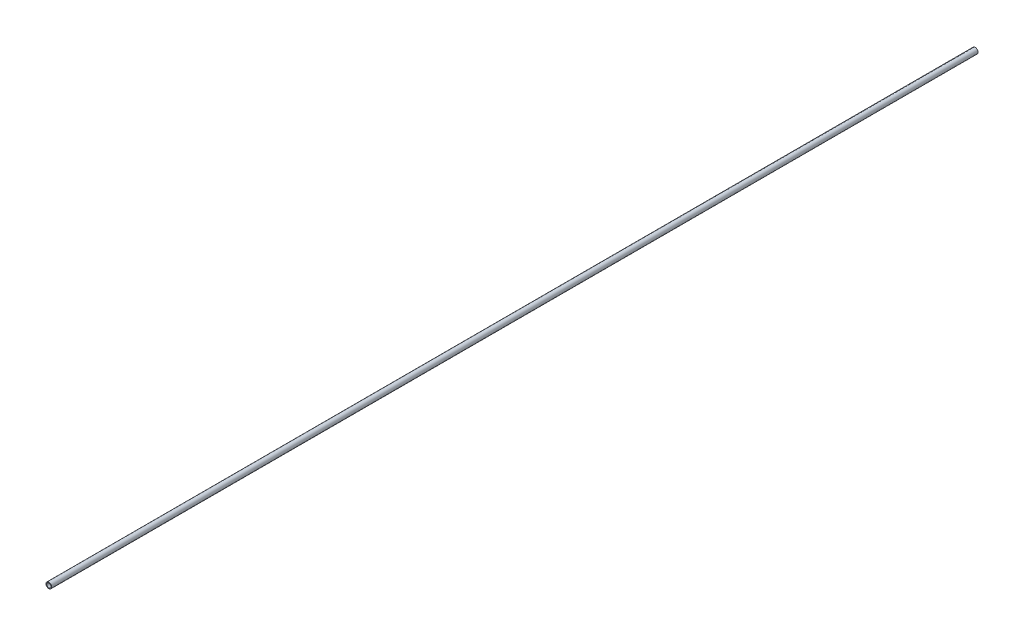
from build123d import *

# Parameters (mm, degrees)
SKETCH1_R           = 10.668
SKETCH1_R_2         = 7.8994
EXTRUDE_THIN1_DEPTH = 1750


with BuildPart() as part:
    # Sketch1 → Extrude-Thin1 (new body, symmetric)
    with BuildSketch(Plane.XY):
        Circle(SKETCH1_R)
        Circle(SKETCH1_R_2, mode=Mode.SUBTRACT)
    extrude(amount=EXTRUDE_THIN1_DEPTH, both=True)


solid = part.part
